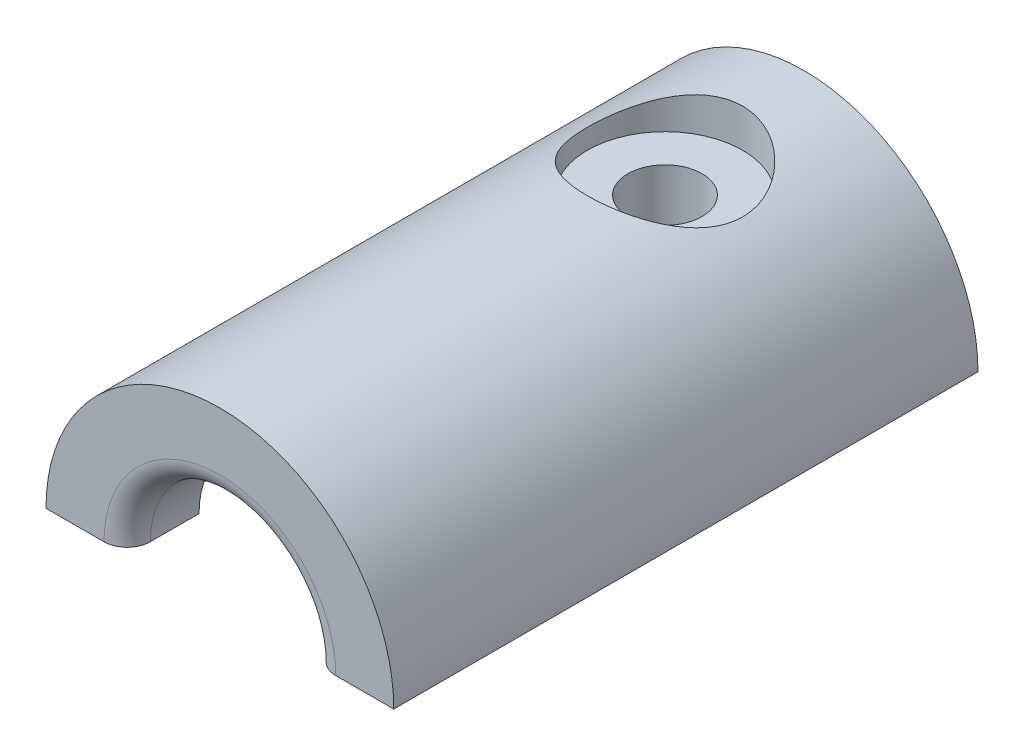
from build123d import *

# Parameters (mm, degrees)
SKETCH1_R                       = 7.5
SKETCH1_R_2                     = 3
BOSS_EXTRUDE1_DEPTH             = 7.5
SKETCH2_R                       = 7.5
SKETCH2_R_2                     = 3
BOSS_EXTRUDE2_DEPTH             = 1
SKETCH3_R                       = 7.5
SKETCH3_R_2                     = 4
BOSS_EXTRUDE3_DEPTH             = 3
SKETCH4_R                       = 7.5
SKETCH4_R_2                     = 5.075
BOSS_EXTRUDE4_DEPTH             = 4.1
SKETCH5_R                       = 7.5
SKETCH5_R_2                     = 4
BOSS_EXTRUDE5_DEPTH             = 3.1
CBORE_FOR_M3_SBHCS1_D           = 3.2
CBORE_FOR_M3_SBHCS1_DEPTH       = 10
CBORE_FOR_M3_SBHCS1_CBORE_D     = 6.7
CBORE_FOR_M3_SBHCS1_CBORE_DEPTH = 1.65
CBORE_FOR_M3_SBHCS1_TIP         = 0.96137699
SKETCH9_W                       = 15
SKETCH9_H                       = 25.2
CUT_EXTRUDE2_DEPTH              = 8.5000001
FILLET1_R                       = 1
FILLET2_R                       = 2


with BuildPart() as part:
    # Sketch1 → Boss-Extrude1 (new body, symmetric)
    with BuildSketch(Plane.XY):
        Circle(SKETCH1_R)
        Circle(SKETCH1_R_2, mode=Mode.SUBTRACT)
    extrude(amount=BOSS_EXTRUDE1_DEPTH, both=True)

    # Sketch2 → Boss-Extrude2 (add)
    with BuildSketch(Plane.XY.offset(7.5)):
        Circle(SKETCH2_R)
        Circle(SKETCH2_R_2, mode=Mode.SUBTRACT)
    extrude(amount=-BOSS_EXTRUDE2_DEPTH)

    # Sketch3 → Boss-Extrude3 (add)
    with BuildSketch(Plane.XY.offset(7.5)):
        Circle(SKETCH3_R)
        Circle(SKETCH3_R_2, mode=Mode.SUBTRACT)
    extrude(amount=BOSS_EXTRUDE3_DEPTH)

    # Sketch4 → Boss-Extrude4 (add)
    with BuildSketch(Plane.XY.offset(10.5)):
        Circle(SKETCH4_R)
        Circle(SKETCH4_R_2, mode=Mode.SUBTRACT)
    extrude(amount=BOSS_EXTRUDE4_DEPTH)

    # Sketch5 → Boss-Extrude5 (add)
    with BuildSketch(Plane.XY.offset(14.6)):
        Circle(SKETCH5_R)
        Circle(SKETCH5_R_2, mode=Mode.SUBTRACT)
    extrude(amount=BOSS_EXTRUDE5_DEPTH)

    # CBORE for M3 SBHCS1
    with Locations(Plane(origin=(0, 7.5, 0), x_dir=(1, 0, 0), z_dir=(0, 1, 0))):
        with Locations((0, 1.5)):
            CounterBoreHole(CBORE_FOR_M3_SBHCS1_D / 2, CBORE_FOR_M3_SBHCS1_CBORE_D / 2, CBORE_FOR_M3_SBHCS1_CBORE_DEPTH, depth=CBORE_FOR_M3_SBHCS1_DEPTH)
            with Locations((0, 0, -(CBORE_FOR_M3_SBHCS1_DEPTH + CBORE_FOR_M3_SBHCS1_TIP / 2))):  # 118° drill point
                Cone(0, CBORE_FOR_M3_SBHCS1_D / 2, CBORE_FOR_M3_SBHCS1_TIP, mode=Mode.SUBTRACT)

    # Sketch9 → Cut-Extrude2 (cut, through all)
    with BuildSketch(Plane(origin=(0, 0, 0), x_dir=(1, 0, 0), z_dir=(0, 1, 0))):
        with Locations((0, -5.1)):
            Rectangle(SKETCH9_W, SKETCH9_H)
    extrude(amount=-CUT_EXTRUDE2_DEPTH, mode=Mode.SUBTRACT)

    # Fillet1
    fillet1_edges = [part.edges().sort_by_distance(p)[0] for p in [
        (0, 4, 17.7),
    ]]
    fillet(fillet1_edges, radius=FILLET1_R)

    # Fillet2
    fillet2_edges = [part.edges().sort_by_distance(p)[0] for p in [
        (0, 3, -7.5),
    ]]
    fillet(fillet2_edges, radius=FILLET2_R)


solid = part.part
